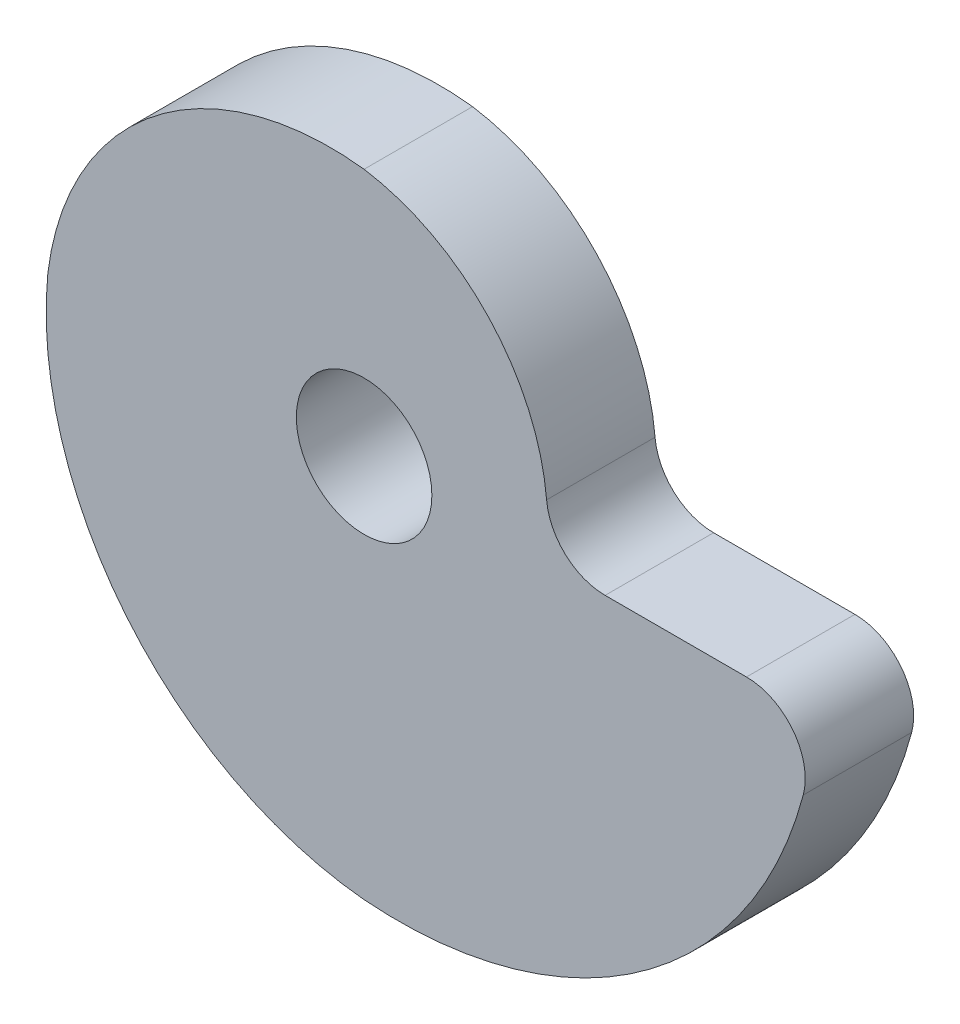
from build123d import *

# Parameters (mm, degrees)
SKETCH1_R           = 3
BOSS_EXTRUDE1_DEPTH = 2.4
FILLET1_R           = 2.6


with BuildPart() as part:
    # Sketch1 → Boss-Extrude1 (new body, symmetric)
    with BuildSketch(Plane.XY):
        with BuildLine():
            Line((8, 0), (20, 0))
            ThreePointArc((20, 0), (13.52081528, -12.642135624), (0, -17))
            ThreePointArc((0, -17), (-10.52081528, -11.399494937), (-14, 0))
            ThreePointArc((-14, 0), (-9.278174593, 8.399494937), (0, 11))
            ThreePointArc((0, 11), (6.278174593, 7.156854249), (8, 0))
        make_face()
        Circle(SKETCH1_R, mode=Mode.SUBTRACT)
    extrude(amount=BOSS_EXTRUDE1_DEPTH, both=True)

    # Fillet1
    fillet1_edges = [part.edges().sort_by_distance(p)[0] for p in [
        (8, 0, 0),
        (20, 0, 0),
    ]]
    fillet(fillet1_edges, radius=FILLET1_R)


solid = part.part
